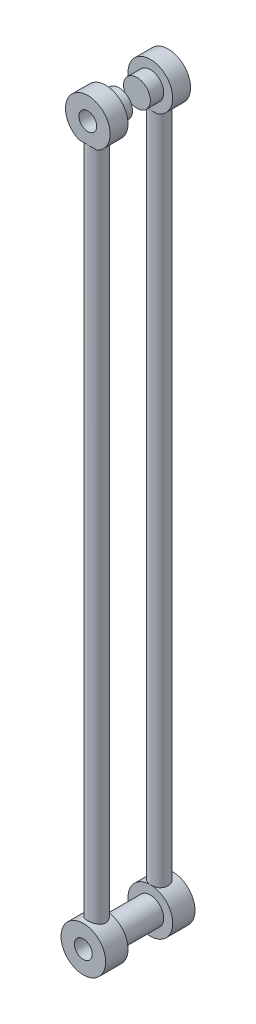
from build123d import *
from build123d.topology import SkipClean

# Parameters (mm, degrees)
SKETCH1_R               = 12.5
SKETCH1_R_2             = 5
BOSS_EXTRUDE1_DEPTH     = 10
CUT_EXTRUDE2_DEPTH      = 21.310096012
SKETCH3_R               = 5
BOSS_EXTRUDE2_DEPTH     = 188
SKETCH5_R               = 12.5
SKETCH5_R_2             = 5
BOSS_EXTRUDE4_DEPTH     = 10
SKETCH7_R               = 7.5
BOSS_EXTRUDE5_DEPTH     = 25
BOSS_EXTRUDE5_2_DEPTH   = 25
SKETCH8_R               = 12.5
SKETCH8_R_2             = 5
BOSS_EXTRUDE6_DEPTH     = 10
BOSS_EXTRUDE6_2_DEPTH   = 10
CUT_EXTRUDE3_DEPTH      = 20
SKETCH12_R              = 5
BOSS_EXTRUDE8_DEPTH     = 380
CUT_EXTRUDE4_DEPTH      = 416.135520155
CUT_EXTRUDE4_DEPTH_BACK = 416.135520155
SKETCH14_R              = 12.5
SKETCH14_R_2            = 5
BOSS_EXTRUDE9_DEPTH     = 2.5
SKETCH15_R              = 12.5
SKETCH15_R_2            = 5
BOSS_EXTRUDE10_DEPTH    = 2.5


with BuildPart() as part:
    # Sketch1 → Boss-Extrude1 (new body)
    with BuildSketch(Plane.XY):
        Circle(SKETCH1_R)
        Circle(SKETCH1_R_2, mode=Mode.SUBTRACT)
    extrude(amount=BOSS_EXTRUDE1_DEPTH)

    # Sketch2 → Cut-Extrude2 (cut, through all)
    with BuildSketch(Plane.XY.offset(10)):
        with BuildLine():
            Line((9.108105184, -12), (3.5, -12))
            ThreePointArc((3.5, -12), (0, -12.5), (-3.5, -12))
            Line((-3.5, -12), (-7.494861462, -12))
            Line((-7.494861462, -12), (-7.494861462, -13.628548532))
            Line((-7.494861462, -13.628548532), (9.511416115, -13.628548532))
            Line((9.511416115, -13.628548532), (9.108105184, -12))
        make_face()
        with BuildLine():
            Line((3.5, -12), (0, -12))
            Line((0, -12), (-3.5, -12))
            ThreePointArc((-3.5, -12), (0, -12.5), (3.5, -12))
        make_face()
    extrude(amount=-CUT_EXTRUDE2_DEPTH, mode=Mode.SUBTRACT)

    # Sketch3 → Boss-Extrude2 (add)
    with BuildSketch(Plane(origin=(0, -12, 0), x_dir=(-1, 0, 0), z_dir=(0, -1, 0))):
        with Locations(Location((0, -5, 0), (0, 0, 90))):
            Circle(SKETCH3_R)
    boss_extrude2 = extrude(amount=BOSS_EXTRUDE2_DEPTH)

    # Mirror2: Boss-Extrude2 across plane
    add(boss_extrude2.mirror(Plane(origin=(0, -200, 5), x_dir=(0, 0, 1), z_dir=(0, -1, 0))))

    # Sketch5 → Boss-Extrude4 (add)
    with SkipClean():  # the faces are left unmerged after this step: merging them gives an invalid solid
        with BuildSketch(Plane.XY):
            with Locations((0, -400)):
                Circle(SKETCH5_R)
            with Locations((0, -400)):
                Circle(SKETCH5_R_2, mode=Mode.SUBTRACT)
        extrude(amount=BOSS_EXTRUDE4_DEPTH)

    # Sketch15 → Boss-Extrude10 (add)
    with SkipClean():  # the faces are left unmerged after this step: merging them gives an invalid solid
        with BuildSketch(Plane(origin=(0, 0, 0), x_dir=(-1, 0, 0), z_dir=(0, 0, -1))):
            with Locations(Location((0, -400, 0), (0, 0, 90))):
                Circle(SKETCH15_R)
            with Locations(Location((0, -400, 0), (0, 0, 180))):
                Circle(SKETCH15_R_2, mode=Mode.SUBTRACT)
        extrude(amount=BOSS_EXTRUDE10_DEPTH)


with BuildPart() as body_2:
    # Sketch7 → Boss-Extrude5 (new body)
    with BuildSketch(Plane.XY.offset(10)):
        Circle(SKETCH7_R)
    extrude(amount=BOSS_EXTRUDE5_DEPTH)

    # Sketch13 → Cut-Extrude4 (cut, two sides)
    with BuildSketch(Plane(origin=(0, 0, 0), x_dir=(0, 0, -1), z_dir=(1, 0, 0))) as cut_extrude4_sk:
        Polygon((-17.5, 7.5), (-22.5, 7.5), (-27.5, 7.5), (-27.5, -15.803446393), (-17.5, -15.803446393), align=None)
    extrude(amount=CUT_EXTRUDE4_DEPTH, mode=Mode.SUBTRACT)
    extrude(cut_extrude4_sk.sketch, amount=-CUT_EXTRUDE4_DEPTH_BACK, mode=Mode.SUBTRACT)


with BuildPart() as body_3:
    # Sketch7 → Boss-Extrude5 2 (new body)
    with BuildSketch(Plane.XY.offset(10)):
        with Locations((0, -400)):
            Circle(SKETCH7_R)
    extrude(amount=BOSS_EXTRUDE5_2_DEPTH)


with BuildPart() as body_4:
    # Sketch8 → Boss-Extrude6 (new body)
    with BuildSketch(Plane.XY.offset(35)):
        Circle(SKETCH8_R)
        Circle(SKETCH8_R_2, mode=Mode.SUBTRACT)
    extrude(amount=BOSS_EXTRUDE6_DEPTH)

    # Sketch9 → Cut-Extrude3 (cut)
    with BuildSketch(Plane.XY.offset(45)):
        Polygon((-5, -12), (-5, -11.456439237), (5, -11.456439237), (5, -13.442017523), align=None)
    extrude(amount=-CUT_EXTRUDE3_DEPTH, mode=Mode.SUBTRACT)



with BuildPart() as body_5:
    # Sketch8 → Boss-Extrude6 2 (new body)
    with BuildSketch(Plane.XY.offset(35)):
        with Locations((0, -400)):
            Circle(SKETCH8_R)
        with Locations((0, -400)):
            Circle(SKETCH8_R_2, mode=Mode.SUBTRACT)
    extrude(amount=BOSS_EXTRUDE6_2_DEPTH)


with BuildPart() as body_4_1:
    with SkipClean():  # the faces are left unmerged after this step: merging them gives an invalid solid
        add(body_4.part)

        add(body_5.part)  # Boss-Extrude8 merges body 5
        # Sketch12 → Boss-Extrude8 (add)
        with BuildSketch(Plane(origin=(0, -11.456439237, 0), x_dir=(-1, 0, 0), z_dir=(0, -1, 0))):
            with Locations(Location((0, -40, 0), (0, 0, 270))):
                Circle(SKETCH12_R)
        extrude(amount=BOSS_EXTRUDE8_DEPTH)

    # Sketch14 → Boss-Extrude9 (add)
    with SkipClean():  # the faces are left unmerged after this step: merging them gives an invalid solid
        with BuildSketch(Plane.XY.offset(45)):
            with Locations(Location((0, -400, 0), (0, 0, 90))):
                Circle(SKETCH14_R)
            with Locations((0, -400)):
                Circle(SKETCH14_R_2, mode=Mode.SUBTRACT)
        extrude(amount=BOSS_EXTRUDE9_DEPTH)


with BuildPart() as cut_extrude4_piece_1:
    # of the separate pieces the step leaves, piece 1, a body of its own (cut_extrude4_pieces)
    add(body_2.part.solids().sort_by_distance((7.5, 0, 10))[0])


with BuildPart() as cut_extrude4_piece_2:
    # of the separate pieces the step leaves, piece 2, a body of its own (cut_extrude4_pieces)
    add(body_2.part.solids().sort_by_distance((7.5, 0, 27.5))[0])


solid = Compound([part.part, body_3.part, body_4_1.part, cut_extrude4_piece_1.part, cut_extrude4_piece_2.part])
